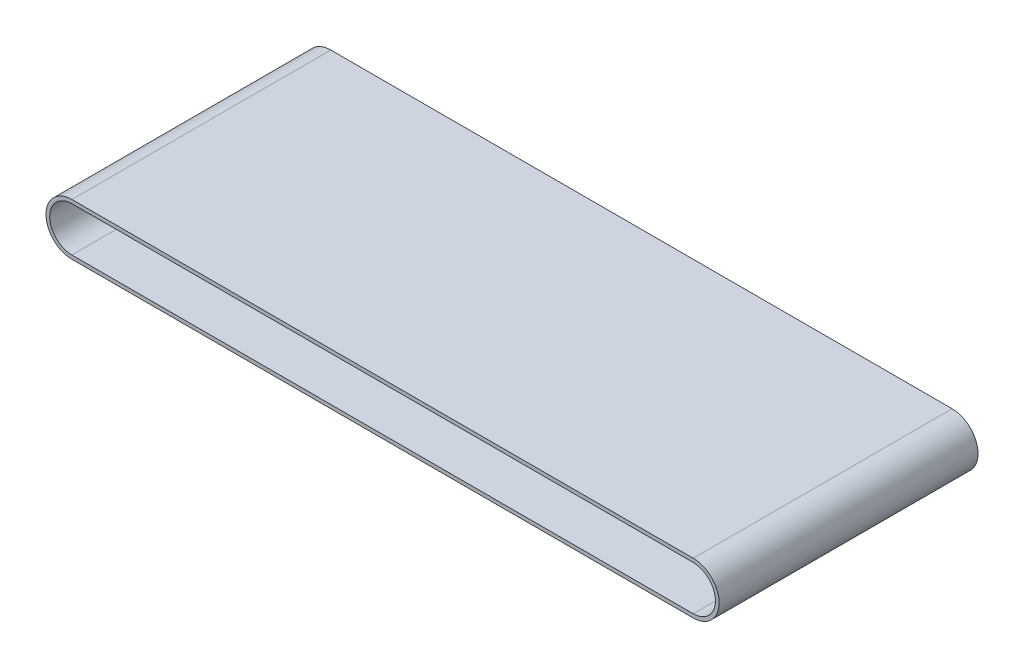
from build123d import *

# Parameters (mm, degrees)
BOSS_EXTRUDE1_DEPTH     = 222.25
CUT_EXTRUDE1_DEPTH      = 1
CUT_EXTRUDE1_DEPTH_BACK = 445.5


with BuildPart() as part:
    # Sketch1 → Boss-Extrude1 (new body, symmetric)
    with BuildSketch(Plane.XY):
        with BuildLine():
            Line((0, 44.45), (1066.8, 44.45))
            ThreePointArc((1066.8, 44.45), (1111.25, 0), (1066.8, -44.45))
            Line((1066.8, -44.45), (0, -44.45))
            ThreePointArc((0, -44.45), (-44.45, 0), (0, 44.45))
        make_face()
    extrude(amount=BOSS_EXTRUDE1_DEPTH, both=True)

    # Sketch2 → Cut-Extrude1 (cut, two sides)
    with BuildSketch(Plane(origin=(0, 0, -222.25), x_dir=(-1, 0, 0), z_dir=(0, 0, -1))) as cut_extrude1_sk:
        with BuildLine():
            Line((-1066.8, 38.1), (0, 38.1))
            ThreePointArc((0, 38.1), (38.1, 0), (0, -38.1))
            Line((0, -38.1), (-1066.8, -38.1))
            ThreePointArc((-1066.8, -38.1), (-1104.9, 0), (-1066.8, 38.1))
        make_face()
    extrude(amount=CUT_EXTRUDE1_DEPTH, mode=Mode.SUBTRACT)
    extrude(cut_extrude1_sk.sketch, amount=-CUT_EXTRUDE1_DEPTH_BACK, mode=Mode.SUBTRACT)


solid = part.part
